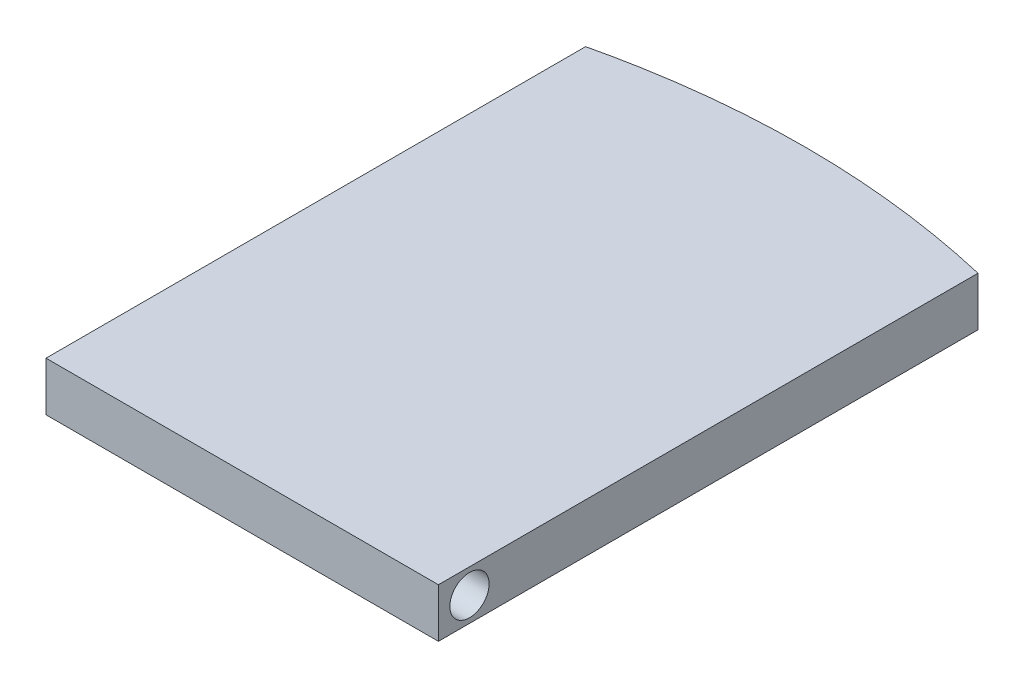
from build123d import *

# Parameters (mm, degrees)
BOSS_EXTRUDE1_DEPTH = 3
SKETCH2_R           = 1.2
CUT_EXTRUDE1_DEPTH  = 7
SKETCH3_R           = 1.2
CUT_EXTRUDE2_DEPTH  = 7
SKETCH4_W           = 24
SKETCH4_H           = 0.6
CUT_EXTRUDE3_DEPTH  = 4.0000001


with BuildPart() as part:
    # Sketch1 → Boss-Extrude1 (new body)
    with BuildSketch(Plane(origin=(0, 0, 0), x_dir=(1, 0, 0), z_dir=(0, 1, 0))):
        with BuildLine():
            Line((0, 0), (24, 0))
            Line((24, 0), (24, 33.6))
            add(Edge.make_bspline(
                [(0, 33.6), (12, 36.4), (24, 33.6)],
                knots=[0, 0, 0, 1, 1, 1], degree=2))
            Line((0, 33.6), (0, 0))
        make_face()
    extrude(amount=BOSS_EXTRUDE1_DEPTH)

    # Sketch2 → Cut-Extrude1 (cut)
    with BuildSketch(Plane(origin=(24, 0, 0), x_dir=(0, 0, -1), z_dir=(1, 0, 0))):
        with Locations((2.5, 1.5)):
            Circle(SKETCH2_R)
    extrude(amount=-CUT_EXTRUDE1_DEPTH, mode=Mode.SUBTRACT)

    # Sketch3 → Cut-Extrude2 (cut)
    with BuildSketch(Plane.ZY):
        with Locations((-2.5, 1.5)):
            Circle(SKETCH3_R)
    extrude(amount=-CUT_EXTRUDE2_DEPTH, mode=Mode.SUBTRACT)

    # Sketch4 → Cut-Extrude3 (cut, through all)
    with BuildSketch(Plane(origin=(0, 3, 0), x_dir=(1, 0, 0), z_dir=(0, 1, 0))):
        with Locations((12, 0.3)):
            Rectangle(SKETCH4_W, SKETCH4_H)
    extrude(amount=-CUT_EXTRUDE3_DEPTH, mode=Mode.SUBTRACT)


solid = part.part
